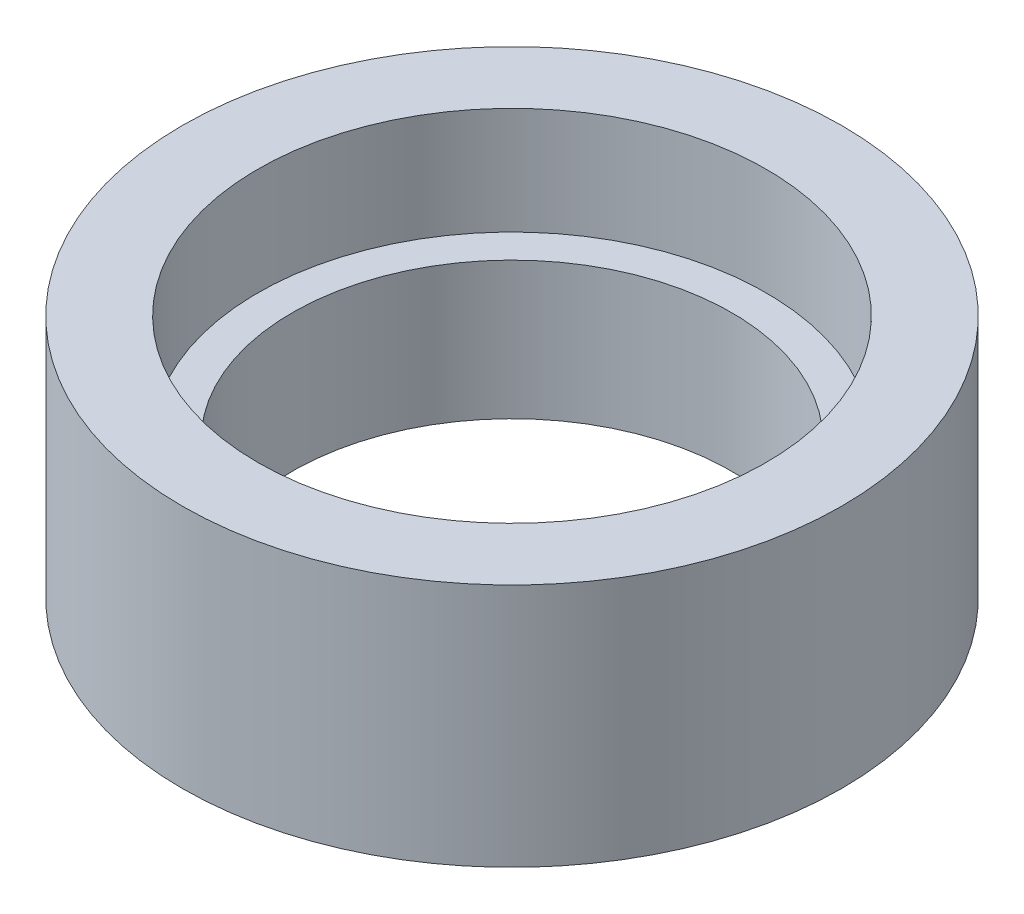
from build123d import *

# Parameters (mm, degrees)
SKETCH_1_R      = 12
SKETCH_1_R_2    = 8
EXTRUDE_1_DEPTH = 5
SKETCH_3_R      = 12
SKETCH_3_R_2    = 9.25
EXTRUDE_2_DEPTH = 3.9


with BuildPart() as part:
    # 草图1 → 凸台-拉伸1 (new body)
    with BuildSketch(Plane(origin=(0, 0, 0), x_dir=(1, 0, 0), z_dir=(0, 1, 0))):
        Circle(SKETCH_1_R)
        Circle(SKETCH_1_R_2, mode=Mode.SUBTRACT)
    extrude(amount=EXTRUDE_1_DEPTH)

    # 草图3 → 凸台-拉伸2 (add)
    with BuildSketch(Plane(origin=(0, 5, 0), x_dir=(1, 0, 0), z_dir=(0, 1, 0))):
        Circle(SKETCH_3_R)
        Circle(SKETCH_3_R_2, mode=Mode.SUBTRACT)
    extrude(amount=EXTRUDE_2_DEPTH)


solid = part.part
